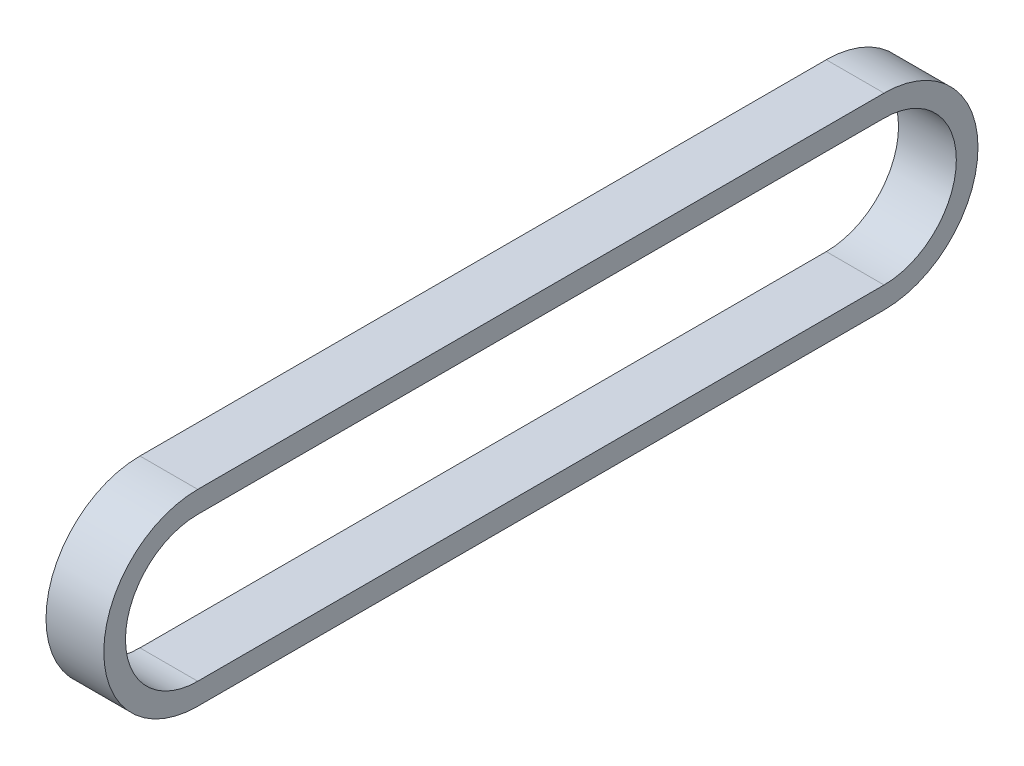
from build123d import *

# Parameters (mm, degrees)
EXTRUDE_1_DEPTH = 8


with BuildPart() as part:
    # 草图1 → 凸台-拉伸1 (new body)
    with BuildSketch(Plane(origin=(0, 0, 0), x_dir=(0, 0, -1), z_dir=(1, 0, 0))):
        with BuildLine():
            Line((0, 23), (95, 23))
            ThreePointArc((95, 23), (108, 10), (95, -3))
            Line((95, -3), (0, -3))
            ThreePointArc((0, -3), (-13, 10), (0, 23))
        make_face()
        with BuildLine():
            Line((0, 0), (95, 0))
            ThreePointArc((95, 0), (105, 10), (95, 20))
            Line((95, 20), (0, 20))
            ThreePointArc((0, 20), (-10, 10), (0, 0))
        make_face(mode=Mode.SUBTRACT)
    extrude(amount=EXTRUDE_1_DEPTH)


solid = part.part
